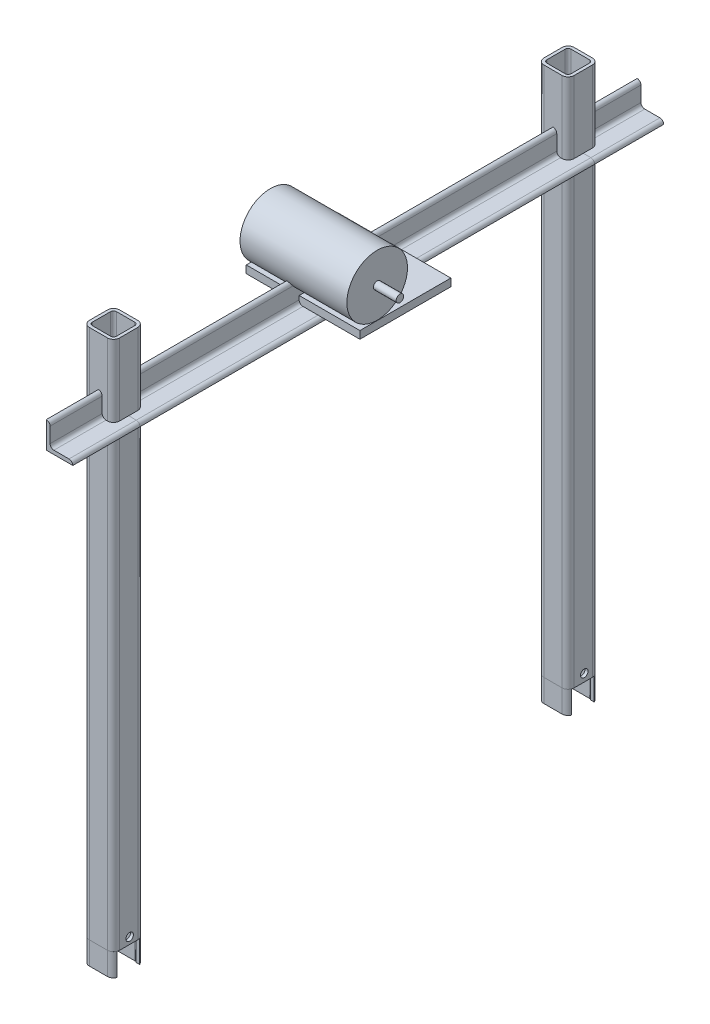
from build123d import *

# Parameters (mm, degrees)
STRUCTURAL_MEMBER1_DEPTH   = 700
STRUCTURAL_MEMBER1_2_DEPTH = 700
STRUCTURAL_MEMBER3_DEPTH   = 30
STRUCTURAL_MEMBER3_2_DEPTH = 30
SKETCH14_W                 = 30
SKETCH14_H                 = 30
CUT_EXTRUDE1_DEPTH         = 45
SKETCH15_W                 = 30
SKETCH15_H                 = 30
CUT_EXTRUDE2_DEPTH         = 45
STRUCTURAL_MEMBER4_DEPTH   = 88.72918051
STRUCTURAL_MEMBER4_2_DEPTH = 600
STRUCTURAL_MEMBER4_3_DEPTH = 91.129530864
SKETCH111_W                = 150
SKETCH111_H                = 120
BOSS_EXTRUDE1_DEPTH        = 10
SKETCH112_R                = 40
BOSS_EXTRUDE2_DEPTH        = 141
SKETCH113_R                = 5
BOSS_EXTRUDE3_DEPTH        = 30
SKETCH114_R                = 5
CUT_EXTRUDE3_DEPTH         = 105


with BuildPart() as part:
    # Sketch11 → Structural Member1 (new body)
    with BuildSketch(Plane(origin=(0, -661.018211614, 53.261571771), x_dir=(0, 0, 1), z_dir=(0, 1, 0))):
        with BuildLine():
            Line((-12, -20), (12, -20))
            ThreePointArc((12, -20), (17.656854249, -17.656854249), (20, -12))
            Line((20, -12), (20, 12))
            ThreePointArc((20, 12), (17.656854249, 17.656854249), (12, 20))
            Line((12, 20), (-12, 20))
            ThreePointArc((-12, 20), (-17.656854249, 17.656854249), (-20, 12))
            Line((-20, 12), (-20, -12))
            ThreePointArc((-20, -12), (-17.656854249, -17.656854249), (-12, -20))
        make_face()
        with BuildLine():
            Line((-12, -16), (12, -16))
            ThreePointArc((12, -16), (14.828427125, -14.828427125), (16, -12))
            Line((16, -12), (16, 12))
            ThreePointArc((16, 12), (14.828427125, 14.828427125), (12, 16))
            Line((12, 16), (-12, 16))
            ThreePointArc((-12, 16), (-14.828427125, 14.828427125), (-16, 12))
            Line((-16, 12), (-16, -12))
            ThreePointArc((-16, -12), (-14.828427125, -14.828427125), (-12, -16))
        make_face(mode=Mode.SUBTRACT)
    extrude(amount=STRUCTURAL_MEMBER1_DEPTH)


with BuildPart() as body_2:
    # Sketch11 on segment 2 (carried to segment 2) → Structural Member1 2 (new body)
    with BuildSketch(Plane(origin=(0, -661.018211614, -546.738428229), x_dir=(0, 0, 1), z_dir=(0, 1, 0))):
        with BuildLine():
            Line((-12, -20), (12, -20))
            ThreePointArc((12, -20), (17.656854249, -17.656854249), (20, -12))
            Line((20, -12), (20, 12))
            ThreePointArc((20, 12), (17.656854249, 17.656854249), (12, 20))
            Line((12, 20), (-12, 20))
            ThreePointArc((-12, 20), (-17.656854249, 17.656854249), (-20, 12))
            Line((-20, 12), (-20, -12))
            ThreePointArc((-20, -12), (-17.656854249, -17.656854249), (-12, -20))
        make_face()
        with BuildLine():
            Line((-12, -16), (12, -16))
            ThreePointArc((12, -16), (14.828427125, -14.828427125), (16, -12))
            Line((16, -12), (16, 12))
            ThreePointArc((16, 12), (14.828427125, 14.828427125), (12, 16))
            Line((12, 16), (-12, 16))
            ThreePointArc((-12, 16), (-14.828427125, 14.828427125), (-16, 12))
            Line((-16, 12), (-16, -12))
            ThreePointArc((-16, -12), (-14.828427125, -14.828427125), (-12, -16))
        make_face(mode=Mode.SUBTRACT)
    extrude(amount=STRUCTURAL_MEMBER1_2_DEPTH)


with BuildPart() as body_3:
    # Sketch13 → Structural Member3 (new body)
    with BuildSketch(Plane(origin=(0, -661.018211614, 53.261571771), x_dir=(0, 0, -1), z_dir=(0, -1, 0))):
        with BuildLine():
            Line((-12, -20), (12, -20))
            ThreePointArc((12, -20), (17.656854249, -17.656854249), (20, -12))
            Line((20, -12), (20, 12))
            ThreePointArc((20, 12), (17.656854249, 17.656854249), (12, 20))
            Line((12, 20), (-12, 20))
            ThreePointArc((-12, 20), (-17.656854249, 17.656854249), (-20, 12))
            Line((-20, 12), (-20, -12))
            ThreePointArc((-20, -12), (-17.656854249, -17.656854249), (-12, -20))
        make_face()
        with BuildLine():
            Line((-12, -16), (12, -16))
            ThreePointArc((12, -16), (14.828427125, -14.828427125), (16, -12))
            Line((16, -12), (16, 12))
            ThreePointArc((16, 12), (14.828427125, 14.828427125), (12, 16))
            Line((12, 16), (-12, 16))
            ThreePointArc((-12, 16), (-14.828427125, 14.828427125), (-16, 12))
            Line((-16, 12), (-16, -12))
            ThreePointArc((-16, -12), (-14.828427125, -14.828427125), (-12, -16))
        make_face(mode=Mode.SUBTRACT)
    extrude(amount=STRUCTURAL_MEMBER3_DEPTH)

    # Sketch15 → Cut-Extrude2 (cut)
    with BuildSketch(Plane.ZY.offset(20)):
        with Locations((53.261571771, -676.018211614)):
            Rectangle(SKETCH15_W, SKETCH15_H)
    extrude(amount=-CUT_EXTRUDE2_DEPTH, mode=Mode.SUBTRACT)


with BuildPart() as body_4:
    # Sketch13 on segment 2 (carried to segment 2) → Structural Member3 2 (new body)
    with BuildSketch(Plane(origin=(0, -661.018211614, -546.738428229), x_dir=(0, 0, -1), z_dir=(0, -1, 0))):
        with BuildLine():
            Line((-12, -20), (12, -20))
            ThreePointArc((12, -20), (17.656854249, -17.656854249), (20, -12))
            Line((20, -12), (20, 12))
            ThreePointArc((20, 12), (17.656854249, 17.656854249), (12, 20))
            Line((12, 20), (-12, 20))
            ThreePointArc((-12, 20), (-17.656854249, 17.656854249), (-20, 12))
            Line((-20, 12), (-20, -12))
            ThreePointArc((-20, -12), (-17.656854249, -17.656854249), (-12, -20))
        make_face()
        with BuildLine():
            Line((-12, -16), (12, -16))
            ThreePointArc((12, -16), (14.828427125, -14.828427125), (16, -12))
            Line((16, -12), (16, 12))
            ThreePointArc((16, 12), (14.828427125, 14.828427125), (12, 16))
            Line((12, 16), (-12, 16))
            ThreePointArc((-12, 16), (-14.828427125, 14.828427125), (-16, 12))
            Line((-16, 12), (-16, -12))
            ThreePointArc((-16, -12), (-14.828427125, -14.828427125), (-12, -16))
        make_face(mode=Mode.SUBTRACT)
    extrude(amount=STRUCTURAL_MEMBER3_2_DEPTH)

    # Sketch14 → Cut-Extrude1 (cut)
    with BuildSketch(Plane.ZY.offset(20)):
        with Locations((-546.738428229, -676.018211614)):
            Rectangle(SKETCH14_W, SKETCH14_H)
    extrude(amount=-CUT_EXTRUDE1_DEPTH, mode=Mode.SUBTRACT)


with BuildPart() as cut_extrude1_piece_1:
    # of the separate pieces the step leaves, piece 1, a body of its own (cut_extrude1_pieces)
    add(body_4.part.solids().sort_by_distance((-12, -661.018211614, -526.738428229))[0])


with BuildPart() as cut_extrude1_piece_2:
    # of the separate pieces the step leaves, piece 2, a body of its own (cut_extrude1_pieces)
    add(body_4.part.solids().sort_by_distance((-19.416198487, -661.018211614, -561.738428229))[0])


with BuildPart() as cut_extrude2_piece_1:
    # of the separate pieces the step leaves, piece 1, a body of its own (cut_extrude2_pieces)
    add(body_3.part.solids().sort_by_distance((-12, -661.018211614, 73.261571771))[0])


with BuildPart() as cut_extrude2_piece_2:
    # of the separate pieces the step leaves, piece 2, a body of its own (cut_extrude2_pieces)
    add(body_3.part.solids().sort_by_distance((-19.416198487, -661.018211614, 38.261571771))[0])


with BuildPart() as body_7:
    # Sketch110 → Structural Member4 (new body)
    with BuildSketch(Plane(origin=(0, -61.018211614, 53.261571771), x_dir=(0, 1, 0), z_dir=(0, 0, -1))):
        with BuildLine():
            Line((0, 0), (0, 35))
            ThreePointArc((0, 35), (3.535533906, 33.535533906), (5, 30))
            Line((5, 30), (5, 10))
            ThreePointArc((5, 10), (6.464466094, 6.464466094), (10, 5))
            Line((10, 5), (30, 5))
            ThreePointArc((30, 5), (33.535533906, 3.535533906), (35, 0))
            Line((35, 0), (0, 0))
        make_face()
    extrude(amount=-STRUCTURAL_MEMBER4_DEPTH)


with BuildPart() as body_8:
    # Sketch110 on segment 2 (carried to segment 2) → Structural Member4 2 (new body)
    with BuildSketch(Plane(origin=(0, -61.018211614, 53.261571771), x_dir=(0, 1, 0), z_dir=(0, 0, -1))):
        with BuildLine():
            Line((0, 0), (0, 35))
            ThreePointArc((0, 35), (3.535533906, 33.535533906), (5, 30))
            Line((5, 30), (5, 10))
            ThreePointArc((5, 10), (6.464466094, 6.464466094), (10, 5))
            Line((10, 5), (30, 5))
            ThreePointArc((30, 5), (33.535533906, 3.535533906), (35, 0))
            Line((35, 0), (0, 0))
        make_face()
    extrude(amount=STRUCTURAL_MEMBER4_2_DEPTH)


with BuildPart() as body_9:
    # Sketch110 on segment 3 (carried to segment 3) → Structural Member4 3 (new body)
    with BuildSketch(Plane(origin=(0, -61.018211614, -546.738428229), x_dir=(0, 1, 0), z_dir=(0, 0, -1))):
        with BuildLine():
            Line((0, 0), (0, 35))
            ThreePointArc((0, 35), (3.535533906, 33.535533906), (5, 30))
            Line((5, 30), (5, 10))
            ThreePointArc((5, 10), (6.464466094, 6.464466094), (10, 5))
            Line((10, 5), (30, 5))
            ThreePointArc((30, 5), (33.535533906, 3.535533906), (35, 0))
            Line((35, 0), (0, 0))
        make_face()
    extrude(amount=STRUCTURAL_MEMBER4_3_DEPTH)


with BuildPart() as body_10:
    # Sketch111 → Boss-Extrude1 (new body)
    with BuildSketch(Plane(origin=(0, -56.018211614, 0), x_dir=(1, 0, 0), z_dir=(0, 1, 0))):
        with Locations((10.163912746, 246.738428229)):
            Rectangle(SKETCH111_W, SKETCH111_H)
    extrude(amount=BOSS_EXTRUDE1_DEPTH)


with BuildPart() as body_11:
    # Sketch112 → Boss-Extrude2 (new body)
    with BuildSketch(Plane(origin=(85.163912746, 0, 0), x_dir=(0, 0, -1), z_dir=(1, 0, 0))):
        with Locations(Location((209.554079822, -5.646199866, 0), (0, 0, 90))):
            Circle(SKETCH112_R)
    extrude(amount=-BOSS_EXTRUDE2_DEPTH)


with BuildPart() as body_12:
    # Sketch113 → Boss-Extrude3 (new body)
    with BuildSketch(Plane(origin=(85.163912746, 0, 0), x_dir=(0, 0, -1), z_dir=(1, 0, 0))):
        with Locations(Location((209.554079822, -5.646199866, 0), (0, 0, 90))):
            Circle(SKETCH113_R)
    extrude(amount=BOSS_EXTRUDE3_DEPTH)


with BuildPart() as cut_extrude3_tool:
    # Sketch114 → Cut-Extrude3 (new body)
    with BuildSketch(Plane(origin=(20, 0, 0), x_dir=(0, 0, -1), z_dir=(1, 0, 0))):
        with Locations((548.040479498, -651.018211614)):
            Circle(SKETCH114_R)
        with Locations((-51.959520502, -652.244300255)):
            Circle(SKETCH114_R)
    extrude(amount=-CUT_EXTRUDE3_DEPTH)


with BuildPart() as part_1:
    add(part.part)

    # Cut-Extrude3: cut by cut_extrude3_tool
    add(cut_extrude3_tool.part, mode=Mode.SUBTRACT)


with BuildPart() as body_2_1:
    add(body_2.part)

    # Cut-Extrude3: cut by cut_extrude3_tool
    add(cut_extrude3_tool.part, mode=Mode.SUBTRACT)


solid = Compound([cut_extrude1_piece_1.part, cut_extrude1_piece_2.part, cut_extrude2_piece_1.part, cut_extrude2_piece_2.part, body_7.part, body_8.part, body_9.part, body_10.part, body_11.part, body_12.part, part_1.part, body_2_1.part])
